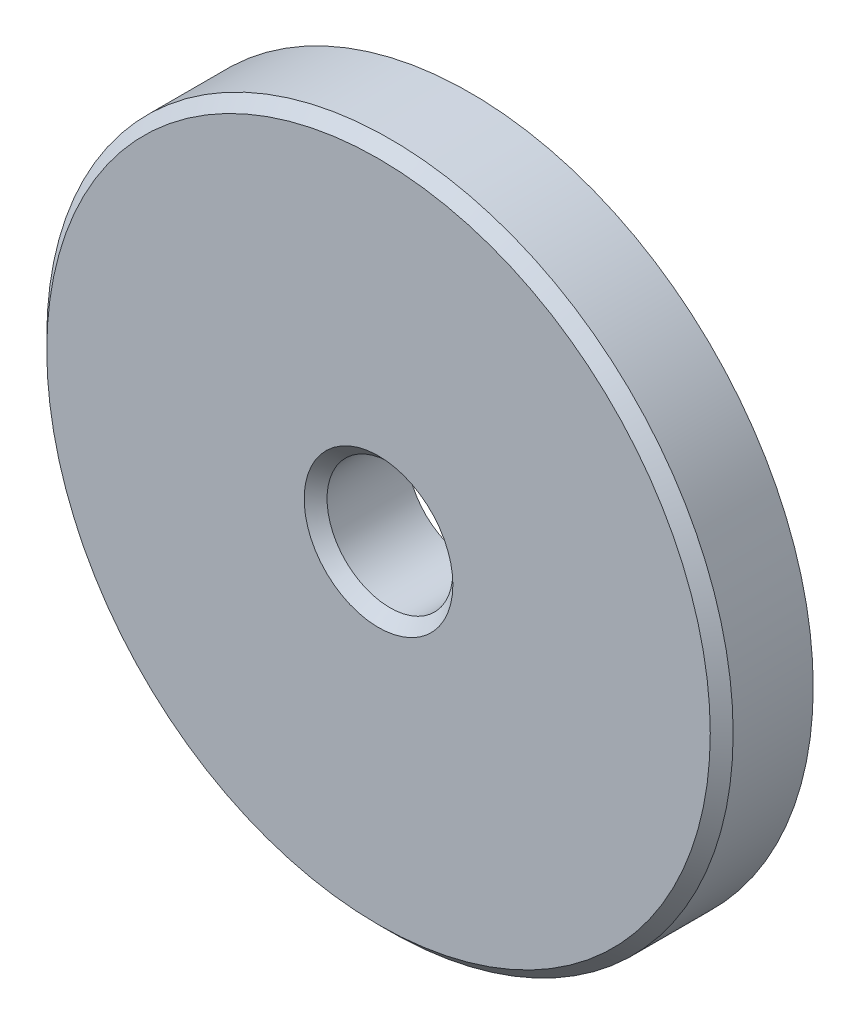
from build123d import *

# Parameters (mm, degrees)
SKETCH_1_R      = 15
SKETCH_1_R_2    = 2.75
EXTRUDE_1_DEPTH = 4
CHAMFER_1_SIZE  = 0.5


with BuildPart() as part:
    # 草图1 → 凸台-拉伸1 (new body)
    with BuildSketch(Plane.XY):
        Circle(SKETCH_1_R)
        Circle(SKETCH_1_R_2, mode=Mode.SUBTRACT)
    extrude(amount=EXTRUDE_1_DEPTH)

    # 倒角1
    chamfer_1_edges = [part.edges().sort_by_distance(p)[0] for p in [
        (-15, 0, 4),
        (-2.75, 0, 4),
    ]]
    chamfer(chamfer_1_edges, length=CHAMFER_1_SIZE)


solid = part.part
